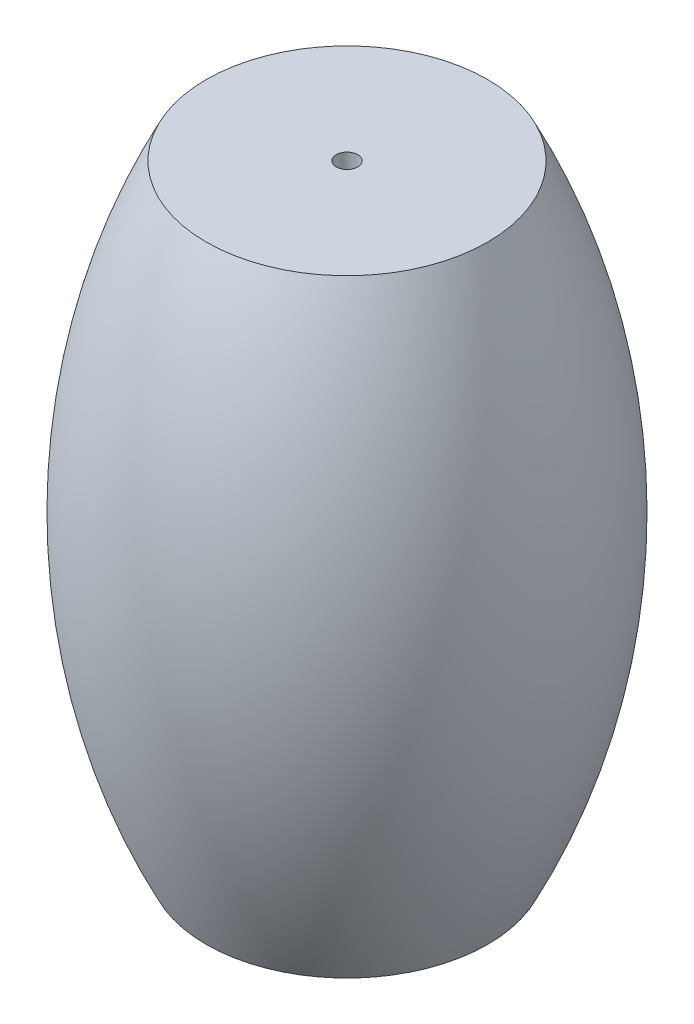
from build123d import *


with BuildPart() as part:
    # Sketch1 → Revolve1 (revolve)
    with BuildSketch(Plane.XY):
        with BuildLine():
            Line((6.09, 0), (0, 0))
            Line((0, 0), (0, 28.477))
            Line((0, 28.477), (6.09, 28.477))
            ThreePointArc((6.09, 28.477), (9.432276473, 14.2385), (6.09, 0))
        make_face()
    revolve(axis=Axis((-0.5, 0, 0), (0, 1, 0)))


solid = part.part
